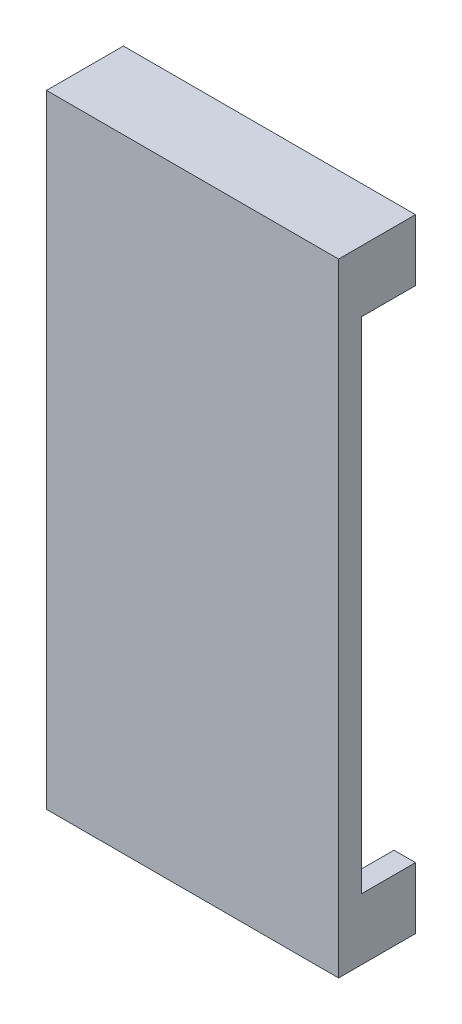
from build123d import *

# Parameters (mm, degrees)
SKETCH1_W           = 38
SKETCH1_H           = 81
BOSS_EXTRUDE1_DEPTH = 3
BOSS_EXTRUDE2_DEPTH = 7


with BuildPart() as part:
    # Sketch1 → Boss-Extrude1 (new body)
    with BuildSketch(Plane.XY):
        with Locations((0, -38)):
            Rectangle(SKETCH1_W, SKETCH1_H)
    extrude(amount=BOSS_EXTRUDE1_DEPTH)

    # Sketch2 → Boss-Extrude2 (add)
    with BuildSketch(Plane(origin=(0, 0, 0), x_dir=(-1, 0, 0), z_dir=(0, 0, -1))):
        Polygon((-19, -5.5), (-19, 2.5), (19, 2.5), (19, -5.5), (16.2, -5.5), (16.2, 1.2), (-16.2, 1.2), (-16.2, -5.5), align=None)
        Polygon((-16.2, -77.2), (16.2, -77.2), (16.2, -70.5), (19, -70.5), (19, -78.5), (-19, -78.5), (-19, -70.5), (-16.2, -70.5), align=None)
    extrude(amount=BOSS_EXTRUDE2_DEPTH)


solid = part.part
